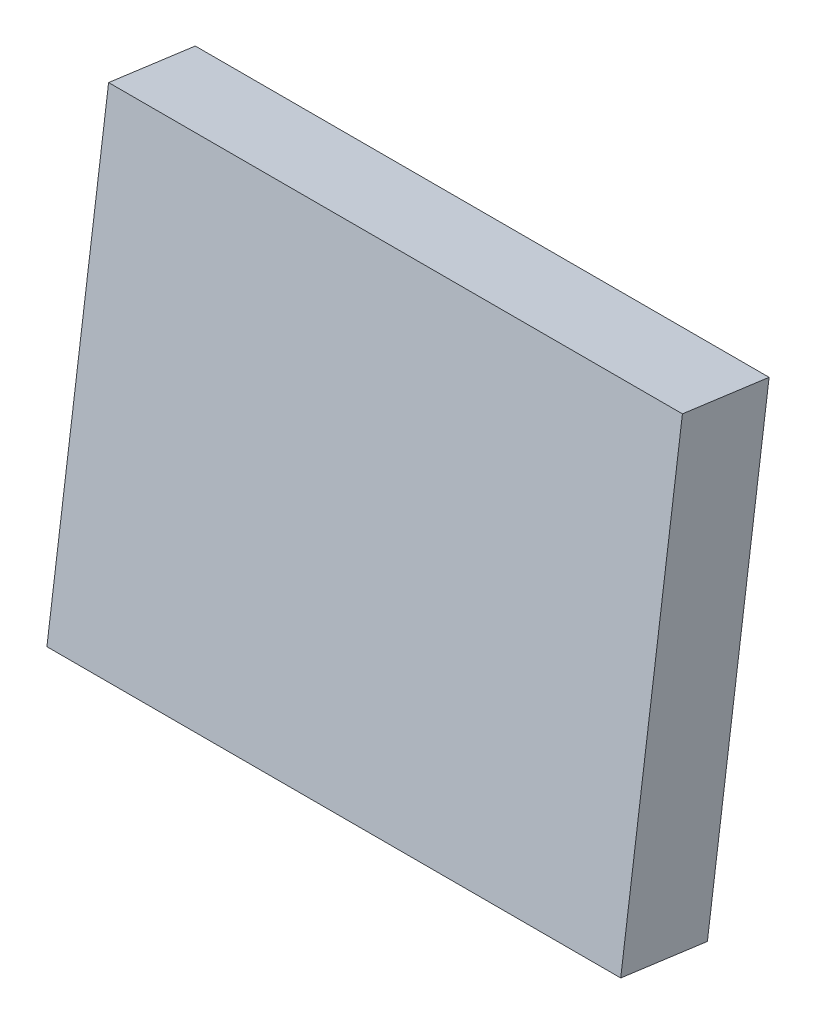
from build123d import *

# Parameters (mm, degrees)
SKETCH2_W           = 32.8
SKETCH2_H           = 26.4
BOSS_EXTRUDE1_DEPTH = 5
SKETCH3_R           = 2
CUT_EXTRUDE1_DEPTH  = 5


with BuildPart() as part:
    # Sketch2 → Boss-Extrude1 (new body)
    with BuildSketch(Plane(origin=(0, -126.565123663, -938.810103229), x_dir=(1, 0, 0), z_dir=(0, -0.133605733, -0.991034565))):
        with Locations((-52.191940296, 12.175776809)):
            Rectangle(SKETCH2_W, SKETCH2_H)
    extrude(amount=BOSS_EXTRUDE1_DEPTH)

    # Sketch3 → Cut-Extrude1 (cut)
    with BuildSketch(Plane(origin=(0, -127.23315233, -943.765276051), x_dir=(1, 0, 0), z_dir=(0, -0.133605733, -0.991034565))):
        with Locations((-56.791940296, -123.221368854)):
            Circle(SKETCH3_R)
        with Locations((-56.791940296, -107.721368854)):
            Circle(SKETCH3_R)
        with Locations((-42.791940296, -123.221368854)):
            Circle(SKETCH3_R)
        with Locations((-42.791940296, -107.721368854)):
            Circle(SKETCH3_R)
    extrude(amount=-CUT_EXTRUDE1_DEPTH, mode=Mode.SUBTRACT)


solid = part.part
